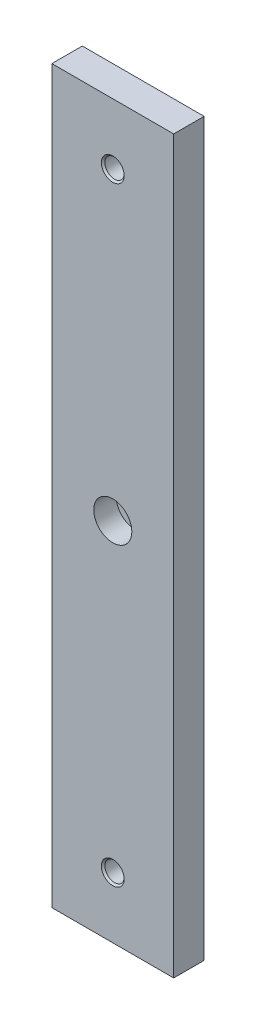
from build123d import *

# Parameters (mm, degrees)
SKETCH1_W_MOCK_PCB_W             = 50.8
SKETCH1_W_MOCK_PCB_H             = 304.8
BOSS_EXTRUDE1_DEPTH              = 6.35
F_3_8_16_TAPPED_HOLE1_AT_2_COUNT = 2
F_3_8_16_TAPPED_HOLE1_AT_2_PITCH = 254
SKETCH3_R                        = 7.9375
CUT_EXTRUDE1_DEPTH               = 9.398


with BuildPart() as part:
    # Sketch1 w/mock PCB → Boss-Extrude1 (new body, symmetric)
    with BuildSketch(Plane.XY):
        Rectangle(SKETCH1_W_MOCK_PCB_W, SKETCH1_W_MOCK_PCB_H)
    extrude(amount=BOSS_EXTRUDE1_DEPTH, both=True)

    # Sketch1 → 3/8-16 Tapped Hole1 (revolve, cut)
    with BuildSketch(Plane(origin=(0, -127, 6.35), x_dir=(0, -1, 0), z_dir=(1, 0, 0))):
        Polygon((0, 0), (0, 12.7), (4.7625, 12.7), (4.03225, 11.96975), (4.03225, 0.73025), (4.7625, 0), align=None)
    f_3_8_16_tapped_hole1 = revolve(axis=Axis((0, -127, 12.7), (0, 0, -1)), mode=Mode.SUBTRACT)

    # 3/8-16 Tapped Hole1 at 2: 3/8-16 Tapped Hole1 ×2
    with Locations(*[(0, i * F_3_8_16_TAPPED_HOLE1_AT_2_PITCH, 0) for i in range(1, F_3_8_16_TAPPED_HOLE1_AT_2_COUNT)]):
        add(f_3_8_16_tapped_hole1, mode=Mode.SUBTRACT)

    # Sketch3 → Cut-Extrude1 (cut)
    with BuildSketch(Plane.XY.offset(6.35)):
        Circle(SKETCH3_R)
    extrude(amount=-CUT_EXTRUDE1_DEPTH, mode=Mode.SUBTRACT)


solid = part.part
